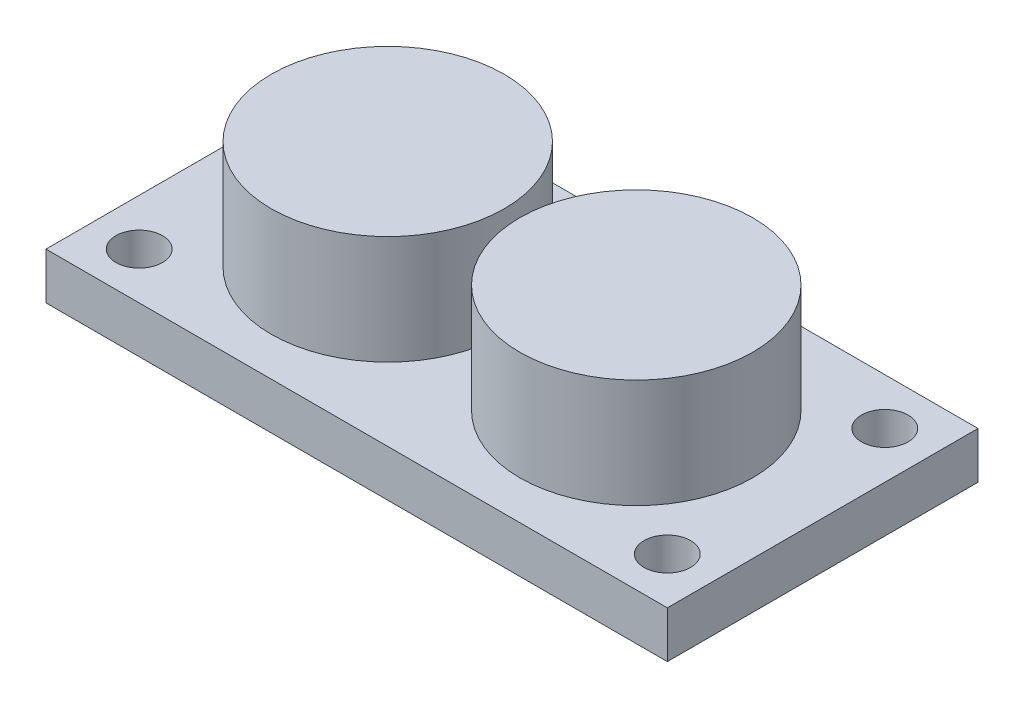
from build123d import *

# Parameters (mm, degrees)
SKETCH1_W           = 40
SKETCH1_H           = 20
SKETCH1_R           = 1.5
SKETCH1_R_2         = 7.5
BOSS_EXTRUDE1_DEPTH = 3
SKETCH1_2_R         = 7.5
BOSS_EXTRUDE2_DEPTH = 10


with BuildPart() as part:
    # Sketch1 → Boss-Extrude1 (new body)
    with BuildSketch(Plane(origin=(0, 0, 0), x_dir=(1, 0, 0), z_dir=(0, 1, 0))):
        with Locations((-0.451467269, -1.151241535)):
            Rectangle(SKETCH1_W, SKETCH1_H)
        with Locations((-17.451467269, 5.848758465)):
            Circle(SKETCH1_R, mode=Mode.SUBTRACT)
        with Locations((-17.451467269, -8.151241535)):
            Circle(SKETCH1_R, mode=Mode.SUBTRACT)
        with Locations((-8.451467269, -1.151241535)):
            Circle(SKETCH1_R_2, mode=Mode.SUBTRACT)
        with Locations((16.548532731, -8.151241535)):
            Circle(SKETCH1_R, mode=Mode.SUBTRACT)
        with Locations((16.548532731, 5.848758465)):
            Circle(SKETCH1_R, mode=Mode.SUBTRACT)
        with Locations((7.548532731, -1.151241535)):
            Circle(SKETCH1_R_2, mode=Mode.SUBTRACT)
    extrude(amount=BOSS_EXTRUDE1_DEPTH)

    # Sketch1_2 → Boss-Extrude2 (add)
    with BuildSketch(Plane(origin=(0, 0, 0), x_dir=(1, 0, 0), z_dir=(0, 1, 0))):
        with Locations((-8.451467269, -1.151241535)):
            Circle(SKETCH1_2_R)
        with Locations((7.548532731, -1.151241535)):
            Circle(SKETCH1_2_R)
    extrude(amount=BOSS_EXTRUDE2_DEPTH)


solid = part.part
